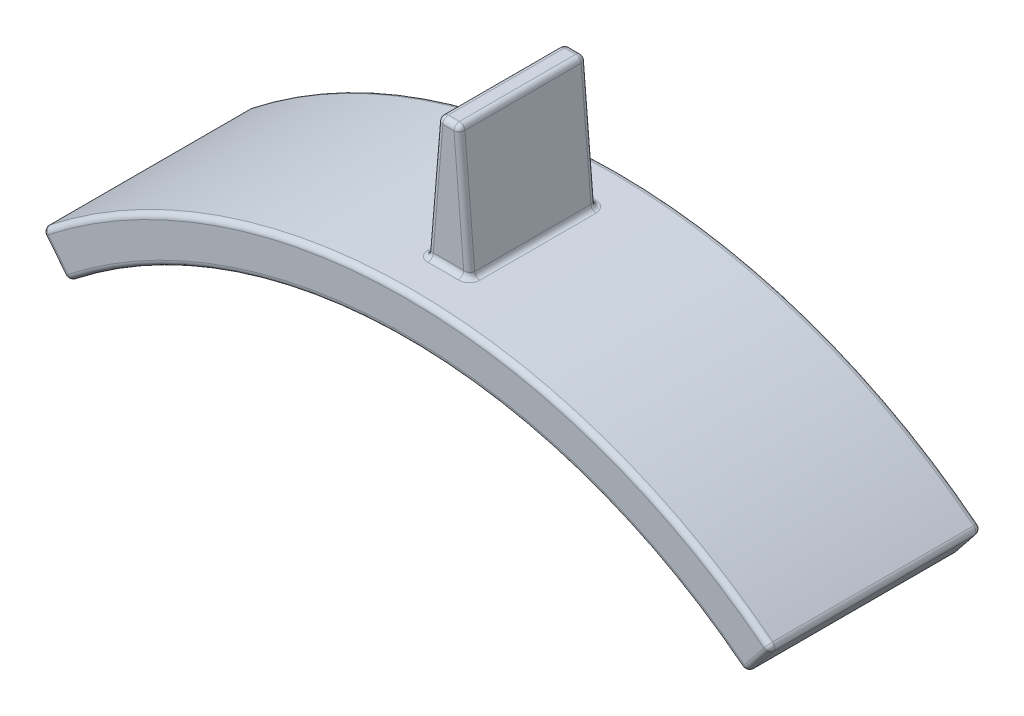
from build123d import *

# Parameters (mm, degrees)
BOSS_EXTRUDE1_DEPTH = 3.96875
BOSS_EXTRUDE2_DEPTH = 2.38125
FILLET1_R           = 0.20483871


with BuildPart() as part:
    # Sketch1 → Boss-Extrude1 (new body, symmetric)
    with BuildSketch(Plane.XY):
        with BuildLine():
            Line((-13.6921875, 17.101536706), (-12.7, 15.862294916))
            ThreePointArc((-12.7, 15.862294916), (0, 20.32), (12.7, 15.862294916))
            Line((12.7, 15.862294916), (13.6921875, 17.101536706))
            ThreePointArc((13.6921875, 17.101536706), (0, 21.9075), (-13.6921875, 17.101536706))
        make_face()
    extrude(amount=BOSS_EXTRUDE1_DEPTH, both=True)

    # Sketch1_3 → Boss-Extrude2 (add, symmetric)
    with BuildSketch(Plane.XY):
        with BuildLine():
            Line((-0.396875, 26.655615749), (-0.79375, 21.893115749))
            ThreePointArc((-0.79375, 21.893115749), (0, 21.9075), (0.79375, 21.893115749))
            Line((0.79375, 21.893115749), (0.396875, 26.655615749))
            Line((0.396875, 26.655615749), (0, 26.655615749))
            Line((0, 26.655615749), (-0.396875, 26.655615749))
        make_face()
    extrude(amount=BOSS_EXTRUDE2_DEPTH, both=True)

    # Fillet1
    fillet1_edges = [part.edges().sort_by_distance(p)[0] for p in [
        (13.19609375, 16.481915811, 3.96875),
        (-0.5953125, 24.274365749, 2.38125),
        (-0.396875, 26.655615749, 0),
        (0, 21.9075, 3.96875),
        (0, 21.9075, -2.38125),
        (-0.79375, 21.893115749, 0),
        (0.5953125, 24.274365749, -2.38125),
        (0.79375, 21.893115749, 0),
        (0, 26.655615749, -2.38125),
        (0.396875, 26.655615749, 0),
        (0, 21.9075, 2.38125),
        (0.5953125, 24.274365749, 2.38125),
        (0, 26.655615749, 2.38125),
        (-0.5953125, 24.274365749, -2.38125),
        (-13.19609375, 16.481915811, 3.96875),
        (0, 21.9075, -3.96875),
        (13.19609375, 16.481915811, -3.96875),
        (0, 20.32, -3.96875),
        (-13.19609375, 16.481915811, -3.96875),
        (-13.6921875, 17.101536706, 0),
        (13.6921875, 17.101536706, 0),
        (12.7, 15.862294916, 0),
        (-12.7, 15.862294916, 0),
        (0, 20.32, 3.96875),
    ]]
    fillet(fillet1_edges, radius=FILLET1_R)


solid = part.part
